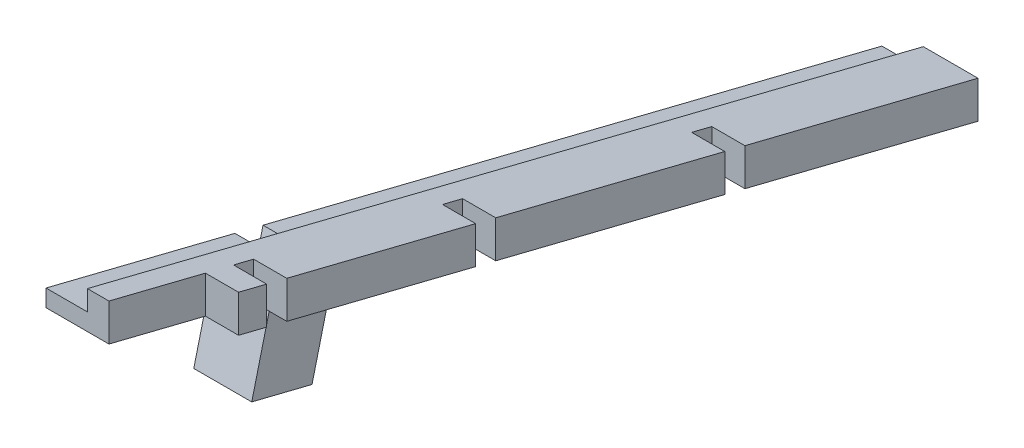
from build123d import *

# Parameters (mm, degrees)
SIDE_COMB_DEPTH           = 4
SIDE_COMB_2_DEPTH         = 4
SIDE_COMB_3_DEPTH         = 4
SIDE_COMB_4_DEPTH         = 4
SIDE_SPACER_DEPTH         = 2.6
NARROW_SUPPORT_DEPTH      = 5
SKETCH7_W                 = 5
SKETCH7_H                 = 3.5
GAP_FOR_SUPPORT_BAR_DEPTH = 2
SUPPORT_BAR_SIDES_DEPTH   = 8.5
SKETCH8_W                 = 7
SKETCH8_H                 = 7.5
SUPPORT_BAR_BOTTOM_DEPTH  = 2


with BuildPart() as part:
    # Sketch1 → Side comb (new body)
    with BuildSketch(Plane(origin=(0, 0, 0), x_dir=(0, 0, -1), z_dir=(1, 0, 0))):
        Polygon((3.396035042, -0.846726635), (0, 0), (0, -4.5), (3.396035042, -5.346726635), align=None)
    extrude(amount=SIDE_COMB_DEPTH)



with BuildPart() as body_2:
    # Sketch1 → Side comb 2 (new body)
    with BuildSketch(Plane(origin=(0, 0, 0), x_dir=(0, 0, -1), z_dir=(1, 0, 0))):
        Polygon((28.623723925, -7.13669592), (5.821774358, -1.451531374), (5.821774358, -5.951531374), (28.623723925, -11.63669592), align=None)
    extrude(amount=SIDE_COMB_2_DEPTH)


with BuildPart() as body_3:
    # Sketch1 → Side comb 3 (new body)
    with BuildSketch(Plane(origin=(0, 0, 0), x_dir=(0, 0, -1), z_dir=(1, 0, 0))):
        Polygon((58.70289144, -14.636274684), (31.049463241, -7.741500659), (31.049463241, -12.241500659), (58.70289144, -19.136274684), align=None)
    extrude(amount=SIDE_COMB_3_DEPTH)


with BuildPart() as body_4:
    # Sketch1 → Side comb 4 (new body)
    with BuildSketch(Plane(origin=(0, 0, 0), x_dir=(0, 0, -1), z_dir=(1, 0, 0))):
        Polygon((89.267206817, -22.256814395), (61.128630755, -15.241079423), (61.128630755, -19.741079423), (89.267206817, -26.756814395), align=None)
    extrude(amount=SIDE_COMB_4_DEPTH)


with BuildPart() as part_1:
    add(part.part)

    add(body_2.part)  # Side spacer merges body 2

    add(body_3.part)  # Side spacer merges body 3

    add(body_4.part)  # Side spacer merges body 4
    # Sketch2 → Side spacer (add)
    with BuildSketch(Plane.ZY):
        Polygon((-89.267206817, -22.256814395), (-89.267206817, -26.756814395), (11.643548715, -1.596937253), (11.643548715, 2.903062747), align=None)
    extrude(amount=SIDE_SPACER_DEPTH)

    # Sketch3 → Narrow support (add)
    with BuildSketch(Plane.ZY.offset(2.6)):
        Polygon((-89.267206817, -24.695587136), (11.643548715, 0.464290006), (11.643548715, -1.596937253), (-89.267206817, -26.756814395), align=None)
    extrude(amount=NARROW_SUPPORT_DEPTH)

    # Sketch7 → Gap for support bar (cut)
    with BuildSketch(Plane(origin=(0, -4.236632084, 1.056311016), x_dir=(1, 0, 0), z_dir=(0, -0.970295726, 0.241921896))):
        with Locations((-5.1, -13.839992525)):
            Rectangle(SKETCH7_W, SKETCH7_H)
    extrude(amount=-GAP_FOR_SUPPORT_BAR_DEPTH, mode=Mode.SUBTRACT)

    # Sketch6 → Support bar sides (add)
    with BuildSketch(Plane(origin=(0, -4.236632084, 1.056311016), x_dir=(1, 0, 0), z_dir=(0, -0.970295726, 0.241921896))):
        Polygon((-2.6, -12.089992525), (-7.6, -12.089992525), (-7.6, -10.089992525), (-0.6, -10.089992525), (-0.6, -17.589992525), (-7.6, -17.589992525), (-7.6, -15.589992525), (-2.6, -15.589992525), align=None)
    extrude(amount=SUPPORT_BAR_SIDES_DEPTH)

    # Sketch8 → Support bar bottom (add)
    with BuildSketch(Plane(origin=(0, -12.484145757, 3.112647129), x_dir=(1, 0, 0), z_dir=(0, -0.970295726, 0.241921896))):
        with Locations((-4.1, -13.839992525)):
            Rectangle(SKETCH8_W, SKETCH8_H)
    extrude(amount=SUPPORT_BAR_BOTTOM_DEPTH)


solid = part_1.part
